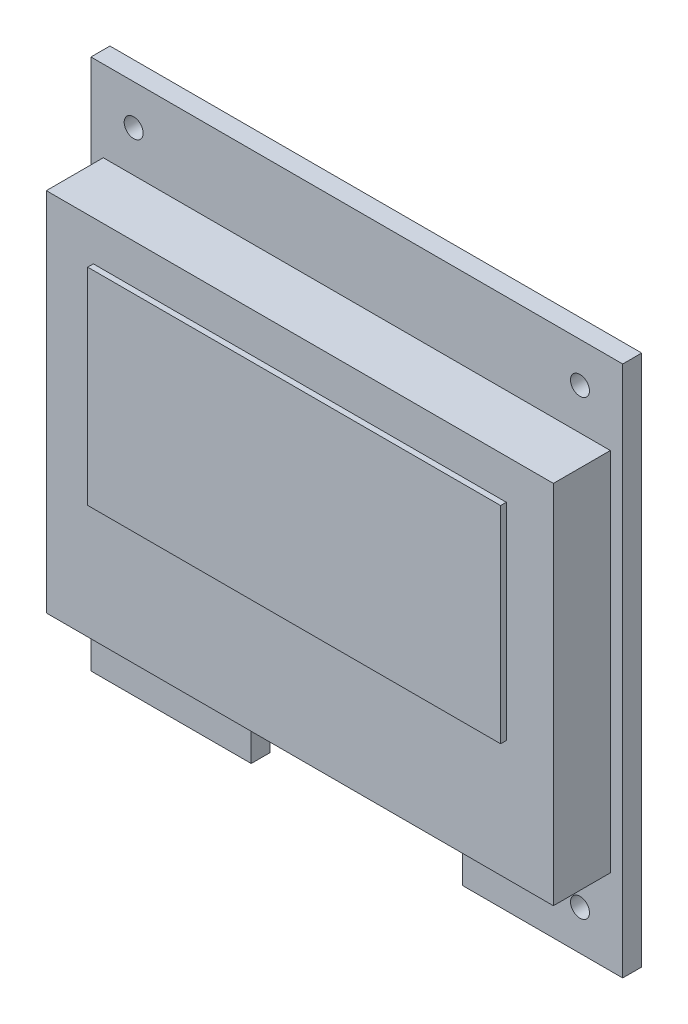
from build123d import *

# Parameters (mm, degrees)
ESQUISSE1_R        = 0.5
BOSS_EXTRU_1_DEPTH = 1
ESQUISSE2_W        = 26.7
ESQUISSE2_H        = 19.26
BOSS_EXTRU_2_DEPTH = 3
ESQUISSE4_W        = 21.744
ESQUISSE4_H        = 10.864
BOSS_EXTRU_3_DEPTH = 0.3


with BuildPart() as part:
    # Esquisse1 → Boss.-Extru.1 (new body)
    with BuildSketch(Plane.XY):
        Polygon((-10.934549339, 15.65387995), (17.065450661, 15.65387995), (17.065450661, -12.34612005), (8.625947463, -12.34612005), (8.625947463, -10.34612005), (3.065450661, -10.34612005), (-2.495046141, -10.34612005), (-2.495046141, -12.34612005), (-10.934549339, -12.34612005), align=None)
        with Locations((-8.684549339, -10.24612005)):
            Circle(ESQUISSE1_R, mode=Mode.SUBTRACT)
        with Locations((-8.684549339, 13.55387995)):
            Circle(ESQUISSE1_R, mode=Mode.SUBTRACT)
        with Locations((14.815450661, 13.55387995)):
            Circle(ESQUISSE1_R, mode=Mode.SUBTRACT)
        with Locations((14.815450661, -10.24612005)):
            Circle(ESQUISSE1_R, mode=Mode.SUBTRACT)
    extrude(amount=BOSS_EXTRU_1_DEPTH)

    # Esquisse2 → Boss.-Extru.2 (add)
    with BuildSketch(Plane.XY.offset(1)):
        with Locations((3.065450661, 1.75387995)):
            Rectangle(ESQUISSE2_W, ESQUISSE2_H)
    extrude(amount=BOSS_EXTRU_2_DEPTH)

    # Esquisse4 → Boss.-Extru.3 (add)
    with BuildSketch(Plane.XY.offset(4)):
        with Locations((3.065450661, 3.85187995)):
            Rectangle(ESQUISSE4_W, ESQUISSE4_H)
    extrude(amount=BOSS_EXTRU_3_DEPTH)


solid = part.part
